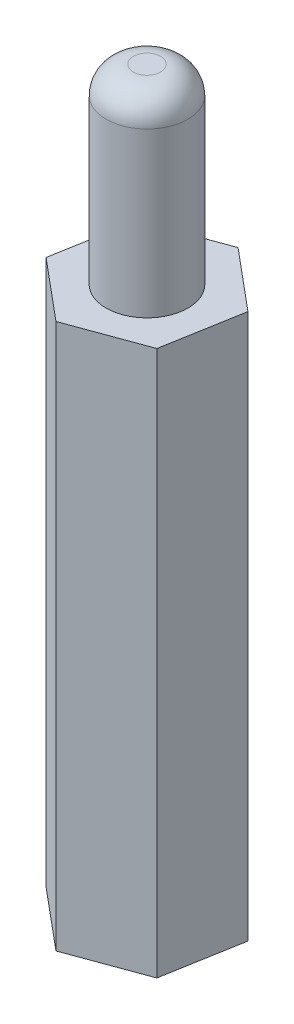
from build123d import *

# Parameters (mm, degrees)
BOSS_EXTRUDE1_DEPTH = 20
SKETCH2_R           = 1.5
BOSS_EXTRUDE2_DEPTH = 7
SKETCH3_R           = 1.5
CUT_EXTRUDE1_DEPTH  = 7
FILLET1_R           = 1


with BuildPart() as part:
    # Sketch1 → Boss-Extrude1 (new body)
    with BuildSketch(Plane(origin=(0, 0, 0), x_dir=(1, 0, 0), z_dir=(0, 1, 0))):
        Polygon((2.214824591, -1.851454932), (2.7108193, 0.992366895), (0.495994709, 2.843821827), (-2.214824591, 1.851454932), (-2.7108193, -0.992366895), (-0.495994709, -2.843821827), align=None)
    extrude(amount=BOSS_EXTRUDE1_DEPTH)

    # Sketch2 → Boss-Extrude2 (add)
    with BuildSketch(Plane(origin=(0, 20, 0), x_dir=(1, 0, 0), z_dir=(0, 1, 0))):
        Circle(SKETCH2_R)
    extrude(amount=BOSS_EXTRUDE2_DEPTH)

    # Sketch3 → Cut-Extrude1 (cut)
    with BuildSketch(Plane.XZ):
        Circle(SKETCH3_R)
    extrude(amount=-CUT_EXTRUDE1_DEPTH, mode=Mode.SUBTRACT)

    # Fillet1
    fillet1_edges = [part.edges().sort_by_distance(p)[0] for p in [
        (-1.5, 27, 0),
    ]]
    fillet(fillet1_edges, radius=FILLET1_R)


solid = part.part
